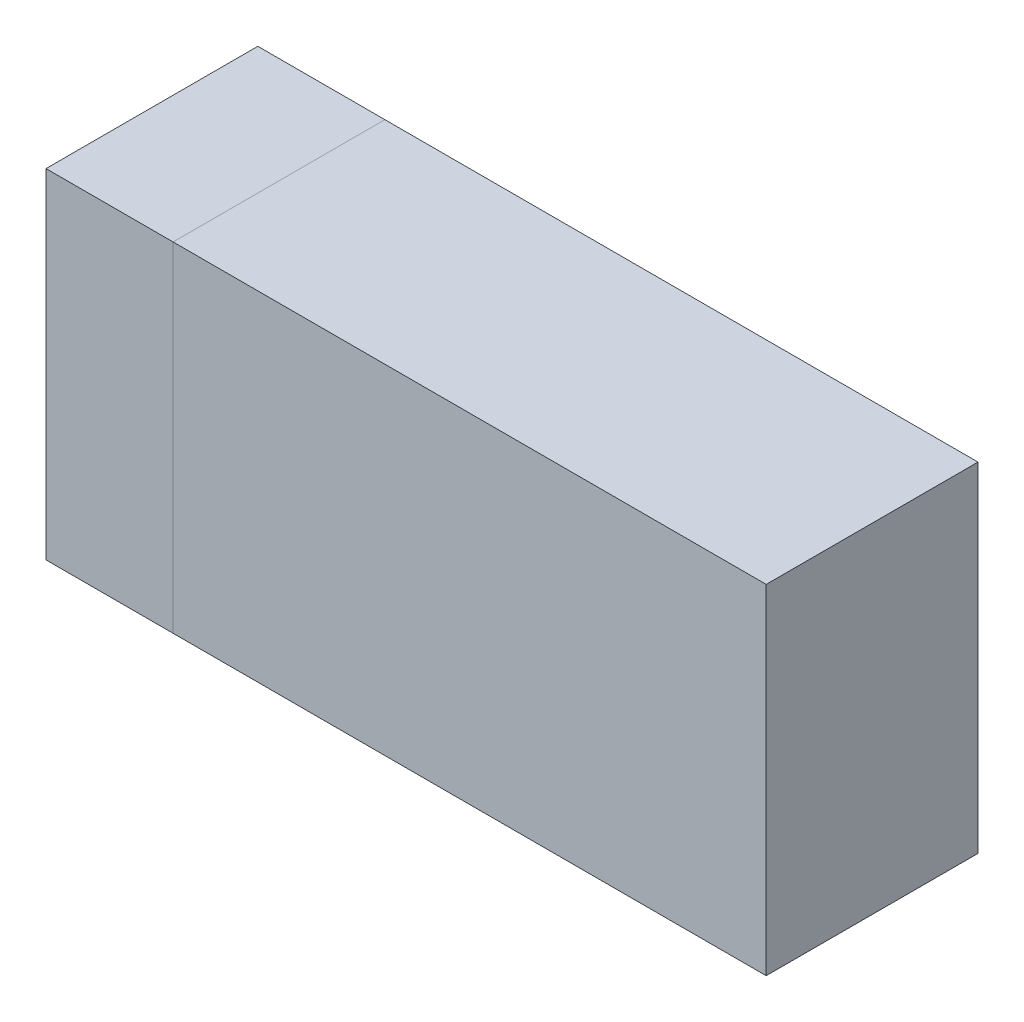
from build123d import *

# Parameters (mm, degrees)
EXTRUDE_1_DEPTH     = 25
SKETCH_2_W          = 3
SKETCH_2_H          = 40
EXTRUDE_2_DEPTH     = 70
SKETCH_4_W          = 5
SKETCH_4_H          = 30
EXTRUDE_3_DEPTH     = 22
SKETCH_11_W         = 3
SKETCH_11_H         = 29.924086267
CUT_EXTRUDE_3_DEPTH = 7
SKETCH_13_W         = 3
SKETCH_13_H         = 30
EXTRUDE_5_DEPTH     = 25
SKETCH_6_W          = 3
SKETCH_6_H          = 5
SKETCH_6_H_2        = 30
SKETCH_6_W_2        = 19
SKETCH_6_W_3        = 22
SKETCH_6_H_3        = 40
EXTRUDE_6_DEPTH     = 15
SKETCH_14_W         = 19
SKETCH_14_H         = 34
SKETCH_14_R         = 4
CUT_EXTRUDE_4_DEPTH = 7
SKETCH_14_2_R       = 4
CUT_EXTRUDE_5_DEPTH = 9


with BuildPart() as part:
    # 스케치1 → 보스-돌출1 (new body)
    with BuildSketch(Plane.XY):
        Polygon((-70, 5), (-70, 0), (0, 0), (0, 40), (-70, 40), (-70, 35), (-5, 35), (-5, 5), align=None)
    extrude(amount=EXTRUDE_1_DEPTH)

    # 스케치2 → 보스-돌출2 (add)
    with BuildSketch(Plane(origin=(0, 0, 0), x_dir=(0, 0, -1), z_dir=(1, 0, 0))):
        with Locations((-23.5, 20)):
            Rectangle(SKETCH_2_W, SKETCH_2_H)
    extrude(amount=-EXTRUDE_2_DEPTH)

    # 스케치4 → 보스-돌출3 (add)
    with BuildSketch(Plane(origin=(0, 0, 22), x_dir=(-1, 0, 0), z_dir=(0, 0, -1))):
        with Locations((57.5, 20)):
            Rectangle(SKETCH_4_W, SKETCH_4_H)
    extrude(amount=EXTRUDE_3_DEPTH)

    # 스케치11 → 컷-돌출3 (cut)
    with BuildSketch(Plane.ZY.offset(60)):
        with Locations((1.5, 20.037956867)):
            Rectangle(SKETCH_11_W, SKETCH_11_H)
    extrude(amount=-CUT_EXTRUDE_3_DEPTH, mode=Mode.SUBTRACT)


with BuildPart() as body_2:
    # 스케치13 → 보스-돌출5 (new body)
    with BuildSketch(Plane.ZY.offset(70)):
        with Locations((1.5, 20.075913733)):
            Rectangle(SKETCH_13_W, SKETCH_13_H)
    extrude(amount=-EXTRUDE_5_DEPTH)

    # 스케치6 → 보스-돌출6 (add)
    with BuildSketch(Plane.ZY.offset(70)):
        with Locations((1.5, 2.5)):
            Rectangle(SKETCH_6_W, SKETCH_6_H)
        with Locations((1.5, 20)):
            Rectangle(SKETCH_6_W, SKETCH_6_H_2)
        with Locations((1.5, 37.5)):
            Rectangle(SKETCH_6_W, SKETCH_6_H)
        with Locations((12.5, 20)):
            Rectangle(SKETCH_6_W_2, SKETCH_6_H_2)
        Polygon((25, 40), (3, 40), (3, 35), (22, 35), (22, 5), (3, 5), (3, 0), (25, 0), align=None)
        with Locations((14, 20)):
            Rectangle(SKETCH_6_W_3, SKETCH_6_H_3)
    extrude(amount=EXTRUDE_6_DEPTH)

    # 스케치14 → 컷-돌출4 (cut)
    with BuildSketch(Plane(origin=(-70, 0, 0), x_dir=(0, 0, -1), z_dir=(1, 0, 0))):
        with Locations((-12.5, 20)):
            Rectangle(SKETCH_14_W, SKETCH_14_H)
        with Locations((-11, 20)):
            Circle(SKETCH_14_R, mode=Mode.SUBTRACT)
    extrude(amount=-CUT_EXTRUDE_4_DEPTH, mode=Mode.SUBTRACT)

    # 스케치14<2> → 컷-돌출5 (cut)
    with BuildSketch(Plane(origin=(-70, 0, 0), x_dir=(0, 0, -1), z_dir=(1, 0, 0))):
        with Locations((-11, 20)):
            Circle(SKETCH_14_2_R)
    extrude(amount=-CUT_EXTRUDE_5_DEPTH, mode=Mode.SUBTRACT)


solid = Compound([part.part, body_2.part])
